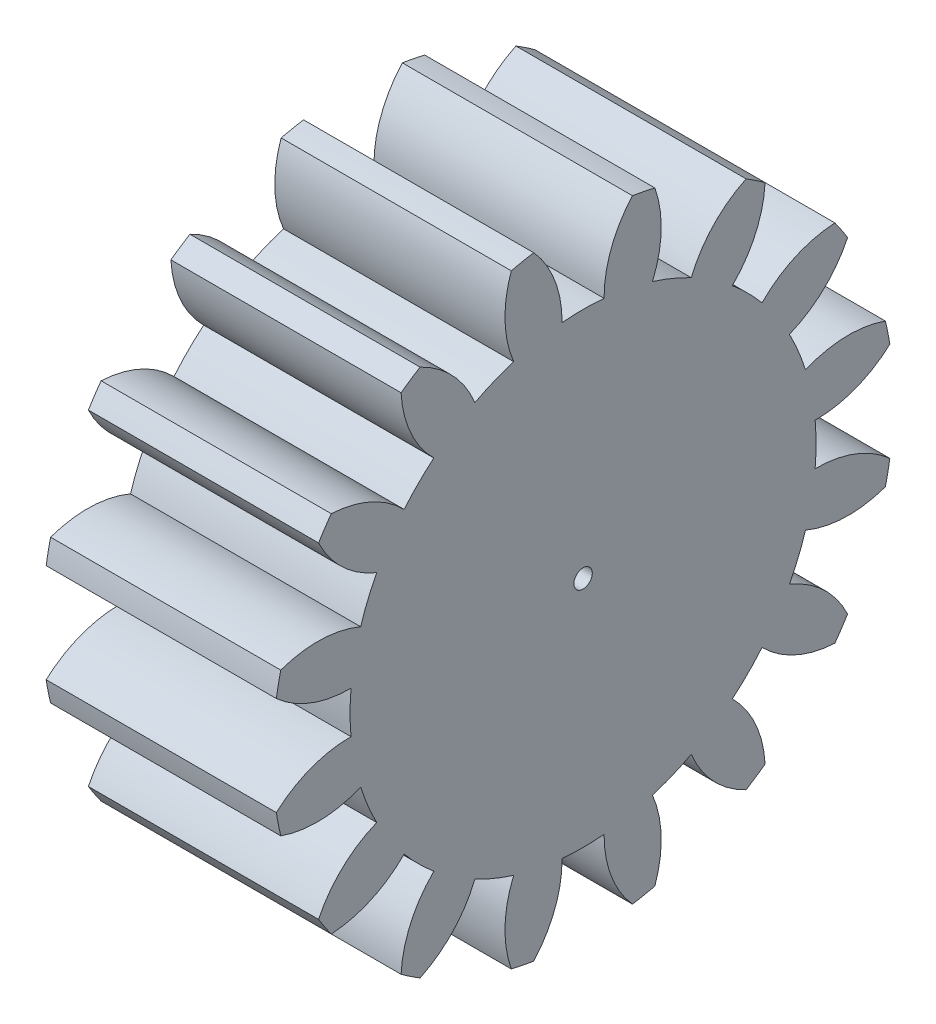
from build123d import *

# Parameters (mm, degrees)
BASPROSKE_W     = 10
BASPROSKE_H     = 13.5
TOOTHCUT_DEPTH  = 22.552262062
TEETHCUTS_COUNT = 16
TEETHCUTS_ANGLE = 337.5
BORSKE_R        = 0.4
BORE_DEPTH      = 50.0000508


with BuildPart() as part:
    # BasProSke → Base-Revolve (revolve)
    with BuildSketch(Plane(origin=(0, 0, 0), x_dir=(1, 0, 0), z_dir=(0, 1, 0)), mode=Mode.PRIVATE) as base_revolve_sk:
        with Locations((5, 6.75)):
            Rectangle(BASPROSKE_W, BASPROSKE_H)
    revolve(base_revolve_sk.sketch.rotate(Axis((-10, 0, 0), (1, 0, 0)), 180), axis=Axis((-10, 0, 0), (1, 0, 0)))

    # TooCutSke → ToothCut (cut, through all)
    with BuildSketch(Plane(origin=(0, 0, 0), x_dir=(0, 0, -1), z_dir=(1, 0, 0))):
        with BuildLine():
            ThreePointArc((0.91215808, 10.08282419), (0, 10.124), (-0.91215808, 10.08282419))
            ThreePointArc((-0.91215808, 10.08282419), (-1.23025345, 11.835184302), (-2.165362868, 13.35094187))
            ThreePointArc((-2.165362868, 13.35094187), (0, 13.5254), (2.165362868, 13.35094187))
            ThreePointArc((2.165362868, 13.35094187), (1.23025345, 11.835184302), (0.91215808, 10.08282419))
        make_face()
    toothcut = extrude(amount=TOOTHCUT_DEPTH, mode=Mode.SUBTRACT)

    # TeethCuts: ToothCut ×16 about axis
    teethcuts_axis = Axis((-10, 0, 0), (1, 0, 0))
    for i in range(1, TEETHCUTS_COUNT):
        add(toothcut.rotate(teethcuts_axis, i * TEETHCUTS_ANGLE / (TEETHCUTS_COUNT - 1)), mode=Mode.SUBTRACT)

    # BorSke → Bore (cut, symmetric)
    with BuildSketch(Plane(origin=(0, 0, 0), x_dir=(0, 0, -1), z_dir=(1, 0, 0))):
        with Locations(Location((0, 0, 0), (0, 0, 180))):
            Circle(BORSKE_R)
    extrude(amount=BORE_DEPTH, both=True, mode=Mode.SUBTRACT)


solid = part.part
